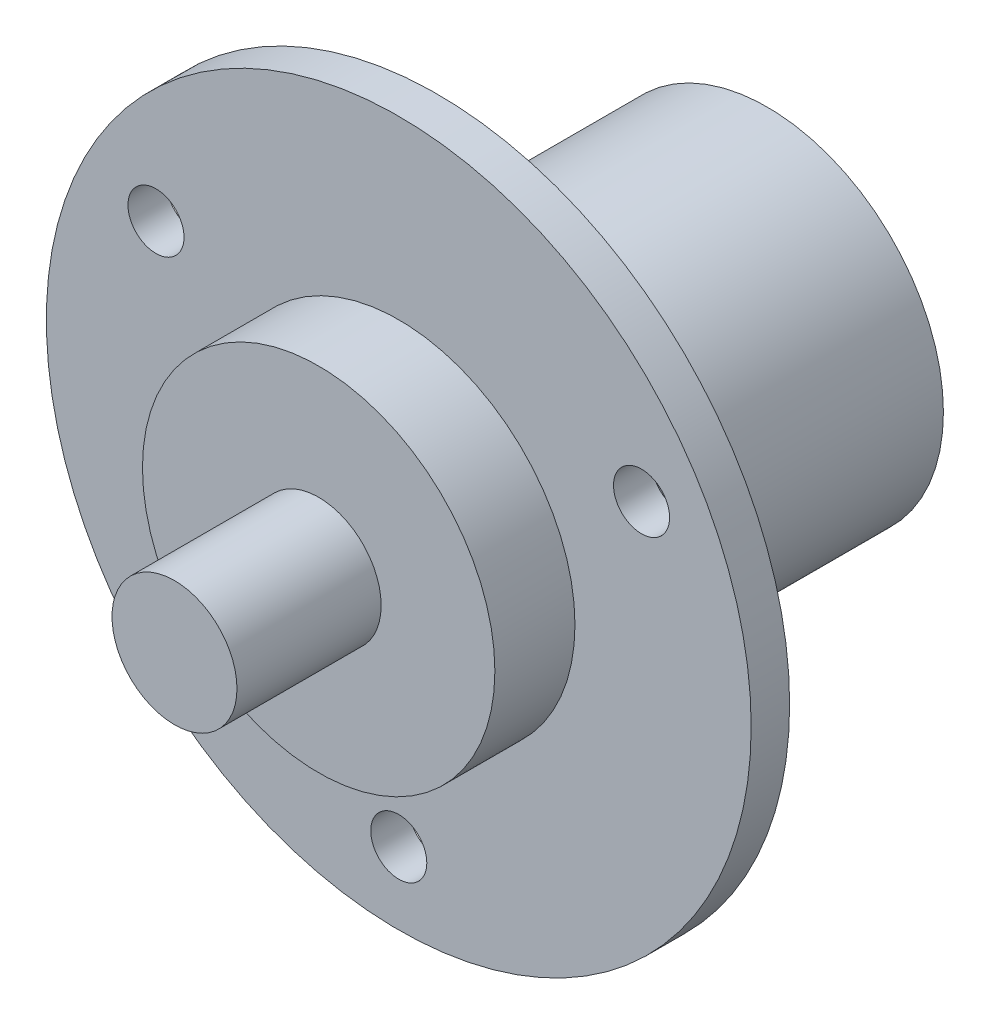
from build123d import *

# Parameters (mm, degrees)
ESQUISSE1_R             = 22
BOSS_EXTRU_1_DEPTH      = 2.4
BOSS_EXTRU_2_DEPTH      = 7.4
BOSS_EXTRU_2_DEPTH_BACK = 20.6
ESQUISSE1_3_R           = 11
ESQUISSE1_4_R           = 3.9
BOSS_EXTRU_3_DEPTH      = 16.4
ESQUISSE1_5_R           = 1.75
ENL_V_MAT_EXTRU_1_DEPTH = 38.314340407


with BuildPart() as part:
    # Esquisse1 → Boss.-Extru.1 (new body)
    with BuildSketch(Plane.XY):
        Circle(ESQUISSE1_R)
    extrude(amount=BOSS_EXTRU_1_DEPTH)

    # Esquisse1_3 → Boss.-Extru.2 (add, two sides: drawn at the far end of the back side and taken through both)
    with BuildSketch(Plane.XY.offset(-BOSS_EXTRU_2_DEPTH_BACK)):
        Circle(ESQUISSE1_3_R)
    extrude(amount=BOSS_EXTRU_2_DEPTH + BOSS_EXTRU_2_DEPTH_BACK)

    # Esquisse1_4 → Boss.-Extru.3 (add)
    with BuildSketch(Plane.XY):
        Circle(ESQUISSE1_4_R)
    extrude(amount=BOSS_EXTRU_3_DEPTH)

    # Esquisse1_5 → Enl_v. mat.-Extru.1 (cut, through all)
    with BuildSketch(Plane.XY):
        with Locations((-15.155444566, 8.75)):
            Circle(ESQUISSE1_5_R)
        with Locations((15.155444566, 8.75)):
            Circle(ESQUISSE1_5_R)
        with Locations((0, -17.5)):
            Circle(ESQUISSE1_5_R)
    extrude(amount=ENL_V_MAT_EXTRU_1_DEPTH, mode=Mode.SUBTRACT)


solid = part.part
